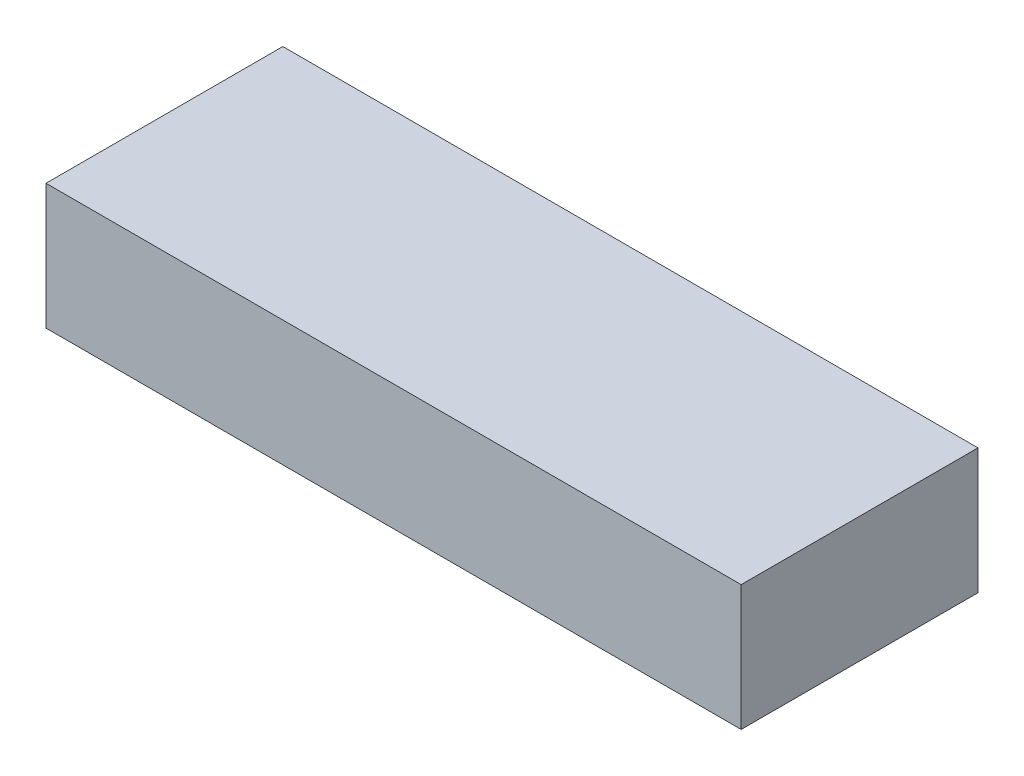
from build123d import *

# Parameters (mm, degrees)
SKETCH1_W           = 137.922
SKETCH1_H           = 46.99
BOSS_EXTRUDE1_DEPTH = 24.892


with BuildPart() as part:
    # Sketch1 → Boss-Extrude1 (new body)
    with BuildSketch(Plane(origin=(0, 0, 0), x_dir=(1, 0, 0), z_dir=(0, 1, 0))):
        Rectangle(SKETCH1_W, SKETCH1_H)
    extrude(amount=BOSS_EXTRUDE1_DEPTH)


solid = part.part
